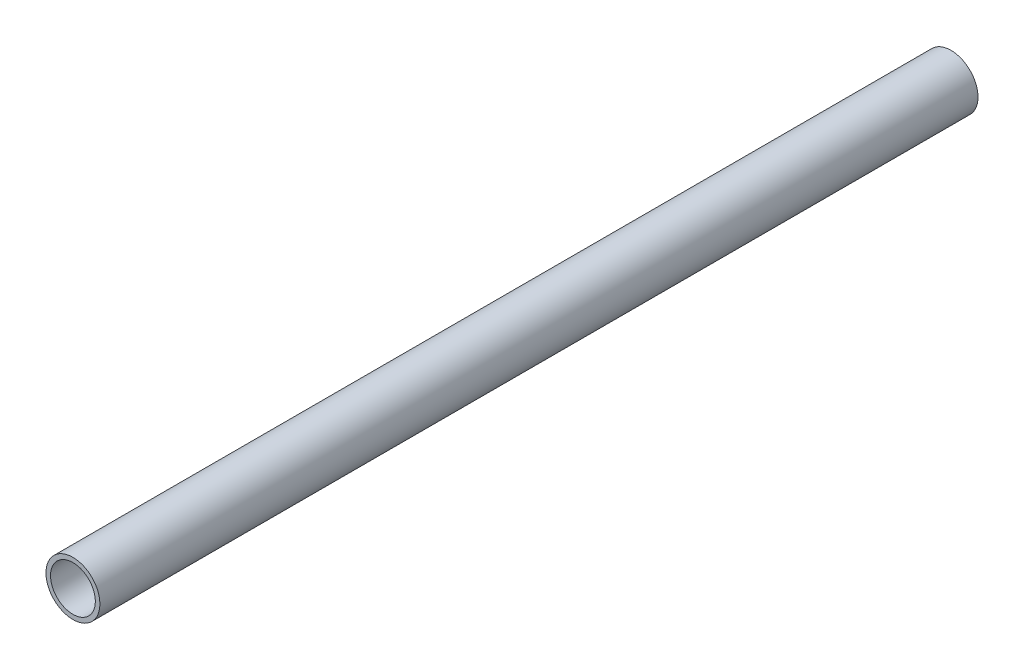
from build123d import *

# Parameters (mm, degrees)
SKETCH1_R           = 21.082
SKETCH1_R_2         = 17.526
BOSS_EXTRUDE1_DEPTH = 686.35583


with BuildPart() as part:
    # Sketch1 → Boss-Extrude1 (new body)
    with BuildSketch(Plane.XY):
        with Locations((164.30625, 199.986383101)):
            Circle(SKETCH1_R)
        with Locations((164.30625, 199.986383101)):
            Circle(SKETCH1_R_2, mode=Mode.SUBTRACT)
    extrude(amount=-BOSS_EXTRUDE1_DEPTH)


solid = part.part
